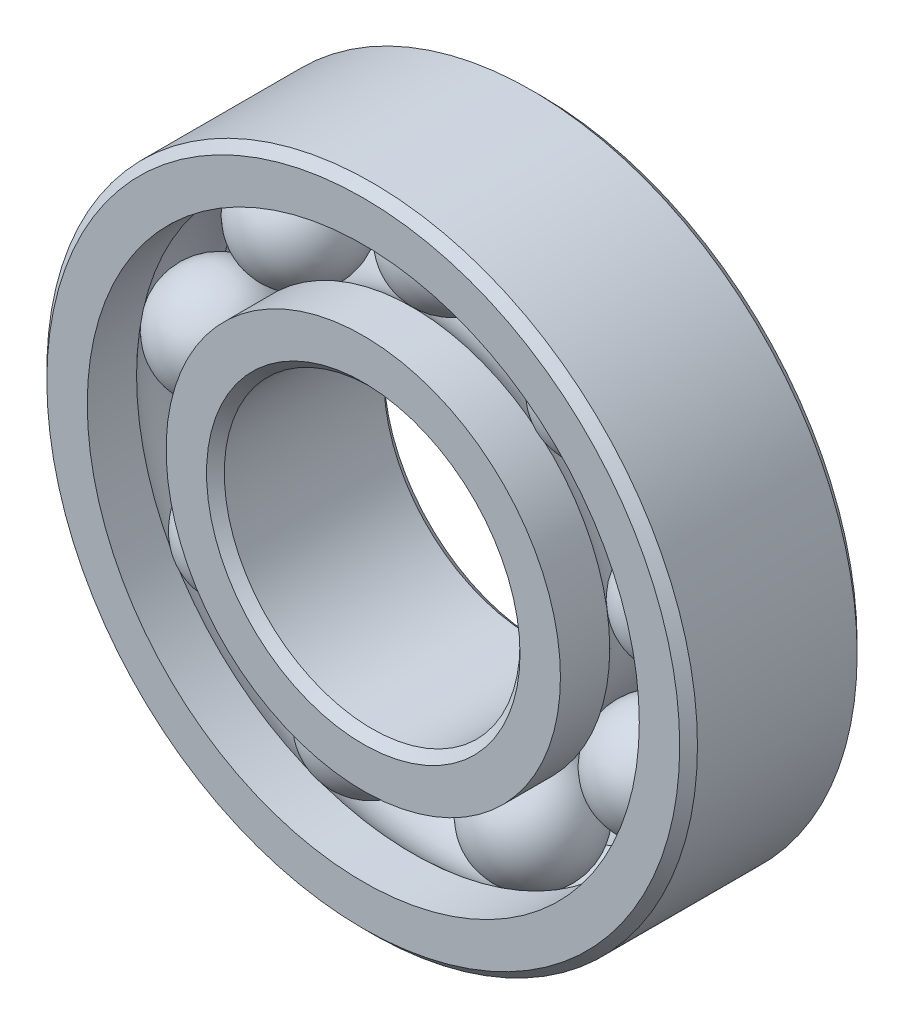
from build123d import *

# Parameters (mm, degrees)
CIRPATTERN1_COUNT = 9


with BuildPart() as part:
    # Sketch5 → Revolve1 (revolve)
    with BuildSketch(Plane(origin=(0, 0, 0), x_dir=(0, 0, -1), z_dir=(1, 0, 0))):
        with BuildLine():
            Line((2.7, 11), (-2.7, 11))
            Line((-2.7, 11), (-3, 10.7))
            Line((-3, 10.7), (-3, 9.333333333))
            Line((-3, 9.333333333), (-1.333333333, 9.333333333))
            ThreePointArc((-1.333333333, 9.333333333), (0, 9.885618083), (1.333333333, 9.333333333))
            Line((1.333333333, 9.333333333), (3, 9.333333333))
            Line((3, 9.333333333), (3, 10.7))
            Line((3, 10.7), (2.7, 11))
        make_face()
    revolve(axis=Axis((0, 0, 3), (0, 0, -1)))


with BuildPart() as body_2:
    # Sketch3 → Revolve3 (revolve)
    with BuildSketch(Plane(origin=(0, 0, 0), x_dir=(0, 0, -1), z_dir=(1, 0, 0))):
        with BuildLine():
            Line((-3, 6.666666667), (-1.333333333, 6.666666667))
            ThreePointArc((-1.333333333, 6.666666667), (0, 6.114381917), (1.333333333, 6.666666667))
            Line((1.333333333, 6.666666667), (3, 6.666666667))
            Line((3, 6.666666667), (3, 5.3))
            Line((3, 5.3), (2.7, 5))
            Line((2.7, 5), (-2.7, 5))
            Line((-2.7, 5), (-3, 5.3))
            Line((-3, 5.3), (-3, 6.666666667))
        make_face()
    revolve(axis=Axis((0, 0, 3), (0, 0, -1)))


with BuildPart() as body_3:
    # Sketch4 → Revolve4 (revolve)
    with BuildSketch(Plane(origin=(0, 0, 0), x_dir=(0, 0, -1), z_dir=(1, 0, 0))):
        with BuildLine():
            Line((-1.885618083, 8), (1.885618083, 8))
            ThreePointArc((1.885618083, 8), (0, 9.885618083), (-1.885618083, 8))
        make_face()
    revolve(axis=Axis((0, 8, 1.885618083), (0, 0, -1)))


with BuildPart() as cirpattern1_1:
    # CirPattern1: pattern copy
    add(body_3.part.rotate(Axis((0, 0, 0), (0, 0, 1)), 1 * 360 / CIRPATTERN1_COUNT))


with BuildPart() as cirpattern1_2:
    # CirPattern1: pattern copy
    add(body_3.part.rotate(Axis((0, 0, 0), (0, 0, 1)), 2 * 360 / CIRPATTERN1_COUNT))


with BuildPart() as cirpattern1_3:
    # CirPattern1: pattern copy
    add(body_3.part.rotate(Axis((0, 0, 0), (0, 0, 1)), 3 * 360 / CIRPATTERN1_COUNT))


with BuildPart() as cirpattern1_4:
    # CirPattern1: pattern copy
    add(body_3.part.rotate(Axis((0, 0, 0), (0, 0, 1)), 4 * 360 / CIRPATTERN1_COUNT))


with BuildPart() as cirpattern1_5:
    # CirPattern1: pattern copy
    add(body_3.part.rotate(Axis((0, 0, 0), (0, 0, 1)), 5 * 360 / CIRPATTERN1_COUNT))


with BuildPart() as cirpattern1_6:
    # CirPattern1: pattern copy
    add(body_3.part.rotate(Axis((0, 0, 0), (0, 0, 1)), 6 * 360 / CIRPATTERN1_COUNT))


with BuildPart() as cirpattern1_7:
    # CirPattern1: pattern copy
    add(body_3.part.rotate(Axis((0, 0, 0), (0, 0, 1)), 7 * 360 / CIRPATTERN1_COUNT))


with BuildPart() as cirpattern1_8:
    # CirPattern1: pattern copy
    add(body_3.part.rotate(Axis((0, 0, 0), (0, 0, 1)), 8 * 360 / CIRPATTERN1_COUNT))


solid = Compound([part.part, body_2.part, body_3.part, cirpattern1_1.part, cirpattern1_2.part, cirpattern1_3.part, cirpattern1_4.part, cirpattern1_5.part, cirpattern1_6.part, cirpattern1_7.part, cirpattern1_8.part])
